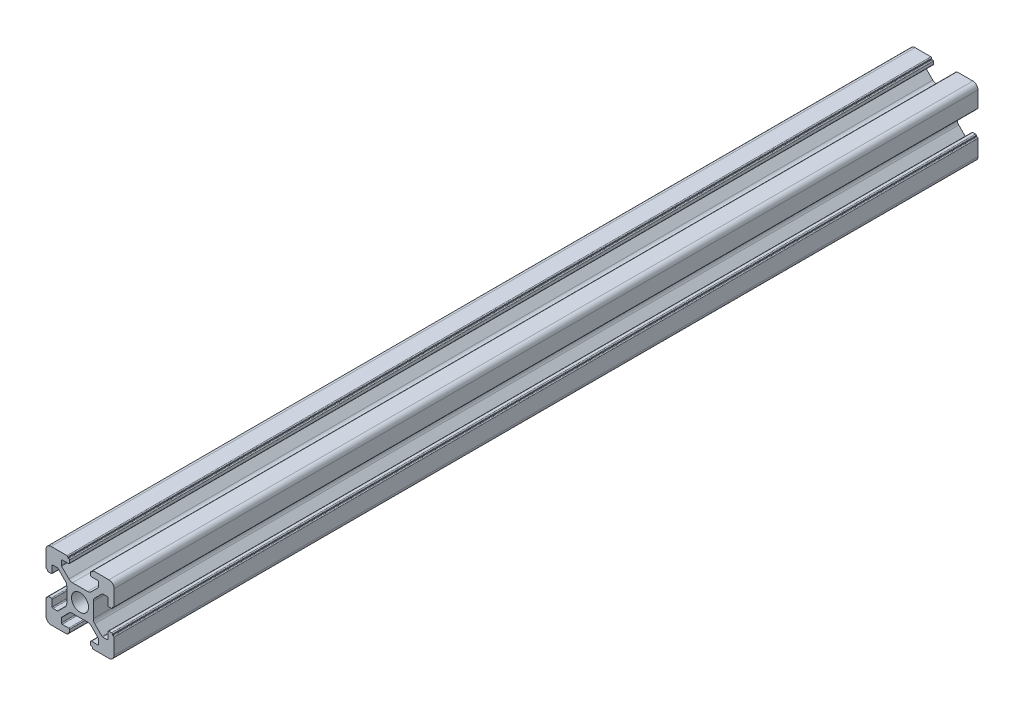
from build123d import *

# Parameters (mm, degrees)
SKETCH_1_R      = 2.5
EXTRUDE_1_DEPTH = 254


with BuildPart() as part:
    # 草图1 → 凸台-拉伸1 (new body)
    with BuildSketch(Plane.XY):
        with BuildLine():
            Line((-8.502261885, -10.002261885), (-3.85, -10.002261885))
            ThreePointArc((-3.85, -10.002261885), (-3.673223305, -9.929038581), (-3.6, -9.752261885))
            Line((-3.6, -9.752261885), (-3.6, -9.502261885))
            Line((-3.6, -9.502261885), (-3.35, -9.502261885))
            ThreePointArc((-3.35, -9.502261885), (-3.173223305, -9.429038581), (-3.1, -9.252261885))
            Line((-3.1, -9.252261885), (-3.1, -8.45))
            ThreePointArc((-3.1, -8.45), (-3.173223305, -8.273223305), (-3.35, -8.2))
            Line((-3.35, -8.2), (-5.25, -8.2))
            ThreePointArc((-5.25, -8.2), (-5.426776695, -8.126776695), (-5.5, -7.95))
            Line((-5.5, -7.95), (-5.5, -6.664213562))
            ThreePointArc((-5.5, -6.664213562), (-5.480969883, -6.568542704), (-5.426776695, -6.487436867))
            Line((-5.426776695, -6.487436867), (-3.278679656, -4.339339828))
            ThreePointArc((-3.278679656, -4.339339828), (-2.792044633, -4.014180701), (-2.218019485, -3.9))
            Line((-2.218019485, -3.9), (2.218019485, -3.9))
            ThreePointArc((2.218019485, -3.9), (2.792044633, -4.014180701), (3.278679656, -4.339339828))
            Line((3.278679656, -4.339339828), (5.426776695, -6.487436867))
            ThreePointArc((5.426776695, -6.487436867), (5.480969883, -6.568542704), (5.5, -6.664213562))
            Line((5.5, -6.664213562), (5.5, -7.95))
            ThreePointArc((5.5, -7.95), (5.426776695, -8.126776695), (5.25, -8.2))
            Line((5.25, -8.2), (3.35, -8.2))
            ThreePointArc((3.35, -8.2), (3.173223305, -8.273223305), (3.1, -8.45))
            Line((3.1, -8.45), (3.1, -9.252261885))
            ThreePointArc((3.1, -9.252261885), (3.173223305, -9.429038581), (3.35, -9.502261885))
            Line((3.35, -9.502261885), (3.6, -9.502261885))
            Line((3.6, -9.502261885), (3.6, -9.752261885))
            ThreePointArc((3.6, -9.752261885), (3.673223305, -9.929038581), (3.85, -10.002261885))
            Line((3.85, -10.002261885), (8.502261885, -10.002261885))
            ThreePointArc((8.502261885, -10.002261885), (9.562922057, -9.562922057), (10.002261885, -8.502261885))
            Line((10.002261885, -8.502261885), (10.002261885, -3.85))
            ThreePointArc((10.002261885, -3.85), (9.929038581, -3.673223305), (9.752261885, -3.6))
            Line((9.752261885, -3.6), (9.502261885, -3.6))
            Line((9.502261885, -3.6), (9.502261885, -3.35))
            ThreePointArc((9.502261885, -3.35), (9.429038581, -3.173223305), (9.252261885, -3.1))
            Line((9.252261885, -3.1), (8.45, -3.1))
            ThreePointArc((8.45, -3.1), (8.273223305, -3.173223305), (8.2, -3.35))
            Line((8.2, -3.35), (8.2, -5.25))
            ThreePointArc((8.2, -5.25), (8.126776695, -5.426776695), (7.95, -5.5))
            Line((7.95, -5.5), (6.664213562, -5.5))
            ThreePointArc((6.664213562, -5.5), (6.568542704, -5.480969883), (6.487436867, -5.426776695))
            Line((6.487436867, -5.426776695), (4.339339828, -3.278679656))
            ThreePointArc((4.339339828, -3.278679656), (4.014180701, -2.792044633), (3.9, -2.218019485))
            Line((3.9, -2.218019485), (3.9, 2.218019485))
            ThreePointArc((3.9, 2.218019485), (4.014180701, 2.792044633), (4.339339828, 3.278679656))
            Line((4.339339828, 3.278679656), (6.487436867, 5.426776695))
            ThreePointArc((6.487436867, 5.426776695), (6.568542704, 5.480969883), (6.664213562, 5.5))
            Line((6.664213562, 5.5), (7.95, 5.5))
            ThreePointArc((7.95, 5.5), (8.126776695, 5.426776695), (8.2, 5.25))
            Line((8.2, 5.25), (8.2, 3.35))
            ThreePointArc((8.2, 3.35), (8.273223305, 3.173223305), (8.45, 3.1))
            Line((8.45, 3.1), (9.252261885, 3.1))
            ThreePointArc((9.252261885, 3.1), (9.429038581, 3.173223305), (9.502261885, 3.35))
            Line((9.502261885, 3.35), (9.502261885, 3.6))
            Line((9.502261885, 3.6), (9.752261885, 3.6))
            ThreePointArc((9.752261885, 3.6), (9.929038581, 3.673223305), (10.002261885, 3.85))
            Line((10.002261885, 3.85), (10.002261885, 8.502261885))
            ThreePointArc((10.002261885, 8.502261885), (9.562922057, 9.562922057), (8.502261885, 10.002261885))
            Line((8.502261885, 10.002261885), (3.85, 10.002261885))
            ThreePointArc((3.85, 10.002261885), (3.673223305, 9.929038581), (3.6, 9.752261885))
            Line((3.6, 9.752261885), (3.6, 9.502261885))
            Line((3.6, 9.502261885), (3.35, 9.502261885))
            ThreePointArc((3.35, 9.502261885), (3.173223305, 9.429038581), (3.1, 9.252261885))
            Line((3.1, 9.252261885), (3.1, 8.45))
            ThreePointArc((3.1, 8.45), (3.173223305, 8.273223305), (3.35, 8.2))
            Line((3.35, 8.2), (5.25, 8.2))
            ThreePointArc((5.25, 8.2), (5.426776695, 8.126776695), (5.5, 7.95))
            Line((5.5, 7.95), (5.5, 6.664213562))
            ThreePointArc((5.5, 6.664213562), (5.480969883, 6.568542704), (5.426776695, 6.487436867))
            Line((5.426776695, 6.487436867), (3.278679656, 4.339339828))
            ThreePointArc((3.278679656, 4.339339828), (2.792044633, 4.014180701), (2.218019485, 3.9))
            Line((2.218019485, 3.9), (-2.218019485, 3.9))
            ThreePointArc((-2.218019485, 3.9), (-2.792044633, 4.014180701), (-3.278679656, 4.339339828))
            Line((-3.278679656, 4.339339828), (-5.426776695, 6.487436867))
            ThreePointArc((-5.426776695, 6.487436867), (-5.480969883, 6.568542704), (-5.5, 6.664213562))
            Line((-5.5, 6.664213562), (-5.5, 7.95))
            ThreePointArc((-5.5, 7.95), (-5.426776695, 8.126776695), (-5.25, 8.2))
            Line((-5.25, 8.2), (-3.35, 8.2))
            ThreePointArc((-3.35, 8.2), (-3.173223305, 8.273223305), (-3.1, 8.45))
            Line((-3.1, 8.45), (-3.1, 9.252261885))
            ThreePointArc((-3.1, 9.252261885), (-3.173223305, 9.429038581), (-3.35, 9.502261885))
            Line((-3.35, 9.502261885), (-3.6, 9.502261885))
            Line((-3.6, 9.502261885), (-3.6, 9.752261885))
            ThreePointArc((-3.6, 9.752261885), (-3.673223305, 9.929038581), (-3.85, 10.002261885))
            Line((-3.85, 10.002261885), (-8.502261885, 10.002261885))
            ThreePointArc((-8.502261885, 10.002261885), (-9.562922057, 9.562922057), (-10.002261885, 8.502261885))
            Line((-10.002261885, 8.502261885), (-10.002261885, 3.85))
            ThreePointArc((-10.002261885, 3.85), (-9.929038581, 3.673223305), (-9.752261885, 3.6))
            Line((-9.752261885, 3.6), (-9.502261885, 3.6))
            Line((-9.502261885, 3.6), (-9.502261885, 3.35))
            ThreePointArc((-9.502261885, 3.35), (-9.429038581, 3.173223305), (-9.252261885, 3.1))
            Line((-9.252261885, 3.1), (-8.45, 3.1))
            ThreePointArc((-8.45, 3.1), (-8.273223305, 3.173223305), (-8.2, 3.35))
            Line((-8.2, 3.35), (-8.2, 5.25))
            ThreePointArc((-8.2, 5.25), (-8.126776695, 5.426776695), (-7.95, 5.5))
            Line((-7.95, 5.5), (-6.664213562, 5.5))
            ThreePointArc((-6.664213562, 5.5), (-6.568542704, 5.480969883), (-6.487436867, 5.426776695))
            Line((-6.487436867, 5.426776695), (-4.339339828, 3.278679656))
            ThreePointArc((-4.339339828, 3.278679656), (-4.014180701, 2.792044633), (-3.9, 2.218019485))
            Line((-3.9, 2.218019485), (-3.9, -2.218019485))
            ThreePointArc((-3.9, -2.218019485), (-4.014180701, -2.792044633), (-4.339339828, -3.278679656))
            Line((-4.339339828, -3.278679656), (-6.487436867, -5.426776695))
            ThreePointArc((-6.487436867, -5.426776695), (-6.568542704, -5.480969883), (-6.664213562, -5.5))
            Line((-6.664213562, -5.5), (-7.95, -5.5))
            ThreePointArc((-7.95, -5.5), (-8.126776695, -5.426776695), (-8.2, -5.25))
            Line((-8.2, -5.25), (-8.2, -3.35))
            ThreePointArc((-8.2, -3.35), (-8.273223305, -3.173223305), (-8.45, -3.1))
            Line((-8.45, -3.1), (-9.252261885, -3.1))
            ThreePointArc((-9.252261885, -3.1), (-9.429038581, -3.173223305), (-9.502261885, -3.35))
            Line((-9.502261885, -3.35), (-9.502261885, -3.6))
            Line((-9.502261885, -3.6), (-9.752261885, -3.6))
            ThreePointArc((-9.752261885, -3.6), (-9.929038581, -3.673223305), (-10.002261885, -3.85))
            Line((-10.002261885, -3.85), (-10.002261885, -8.502261885))
            ThreePointArc((-10.002261885, -8.502261885), (-9.562922057, -9.562922057), (-8.502261885, -10.002261885))
        make_face()
        Circle(SKETCH_1_R, mode=Mode.SUBTRACT)
    extrude(amount=EXTRUDE_1_DEPTH)


solid = part.part
